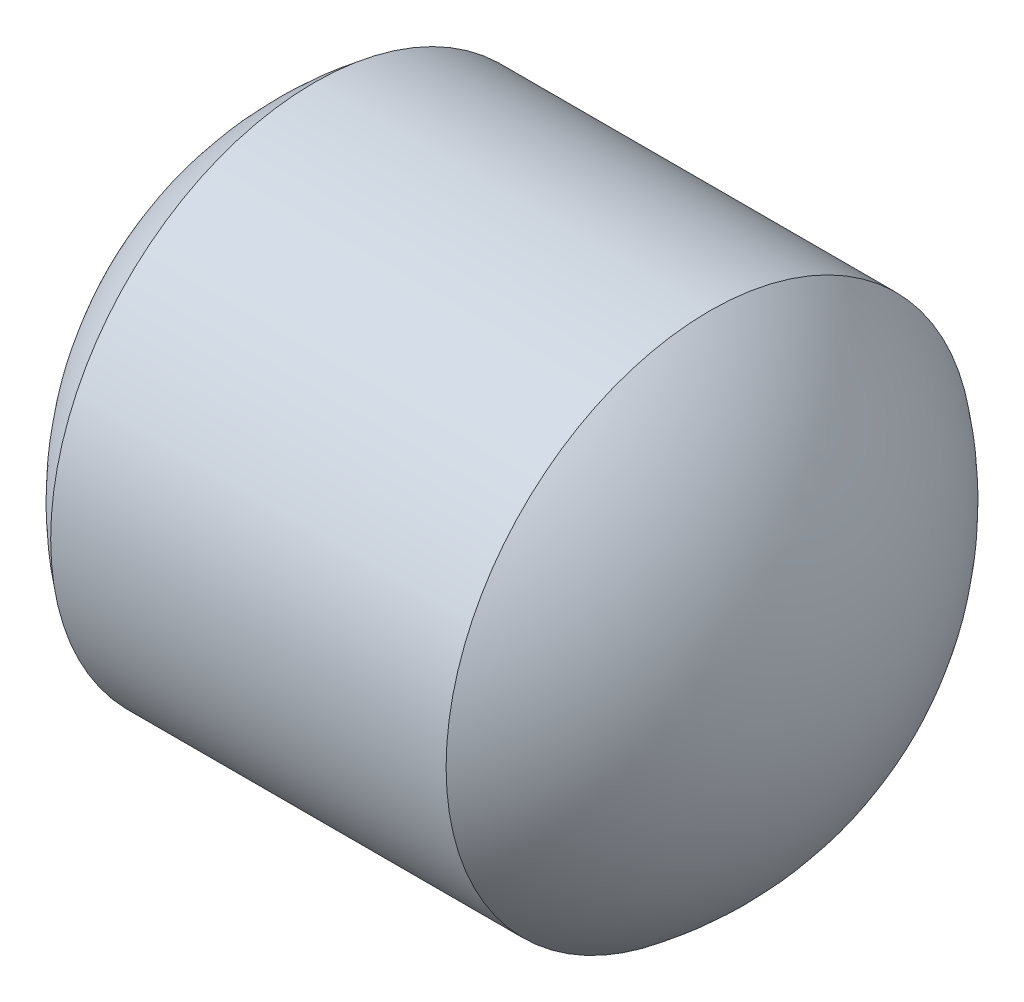
from build123d import *

# Parameters (mm, degrees)
SKETCH_1_ONE_SIDE_W = 2.99940003
SKETCH_1_ONE_SIDE_H = 1.99960002


with BuildPart() as part:
    # 草图1 one side → 旋转1 (revolve)
    with BuildSketch(Plane.XY):
        with Locations((3432.954240112, 1942.195597406)):
            Rectangle(SKETCH_1_ONE_SIDE_W, SKETCH_1_ONE_SIDE_H)
        with BuildLine():
            Line((3430.454740087, 1941.195797396), (3431.454540097, 1941.195797396))
            Line((3431.454540097, 1941.195797396), (3431.454540097, 1943.195397416))
            ThreePointArc((3431.454540097, 1943.195397416), (3430.718619326, 1942.313607789), (3430.454740087, 1941.195797396))
        make_face()
        with BuildLine():
            Line((3434.453940127, 1941.195797396), (3435.453740137, 1941.195797396))
            ThreePointArc((3435.453740137, 1941.195797396), (3435.189860898, 1942.313607789), (3434.453940127, 1943.195397416))
            Line((3434.453940127, 1943.195397416), (3434.453940127, 1941.195797396))
        make_face()
    revolve(axis=Axis((3430.032166875, 1941.195797396, 0), (1, 0, 0)))


solid = part.part
